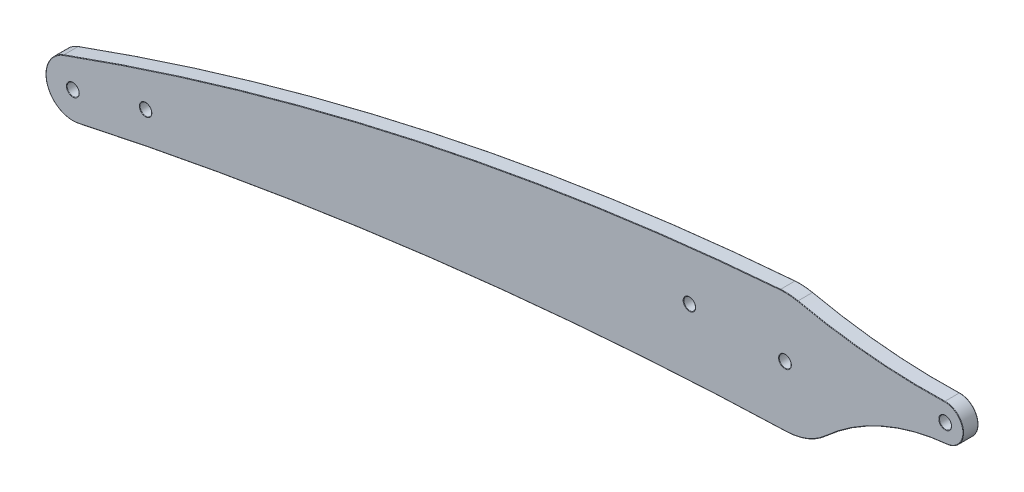
from build123d import *

# Parameters (mm, degrees)
SKETCH1_R           = 2
SKETCH1_R_2         = 1.95
BOSS_EXTRUDE1_DEPTH = 5
FILLET1_R           = 0.15


with BuildPart() as part:
    # Sketch1 → Boss-Extrude1 (new body)
    with BuildSketch(Plane.XY):
        with BuildLine():
            ThreePointArc((-276.780298859, 247.280879976), (-159.458245776, 281.177252724), (-38.627454071, 298.878891089))
            ThreePointArc((-38.627454071, 298.878891089), (-35.703409549, 298.891758843), (-32.808740213, 298.478126912))
            ThreePointArc((-32.808740213, 298.478126912), (-8.553336403, 294.720430459), (15.979700244, 293.96213667))
            ThreePointArc((15.979700244, 293.96213667), (22.150729095, 288.343420795), (16.736284207, 281.992408929))
            ThreePointArc((16.736284207, 281.992408929), (-4.892396072, 276.328147292), (-23.631877288, 264.133250235))
            ThreePointArc((-23.631877288, 264.133250235), (-29.582680643, 260.39649995), (-36.45865167, 258.948609866))
            ThreePointArc((-36.45865167, 258.948609866), (-154.786824819, 249.865033835), (-271.793567605, 230.028450028))
            ThreePointArc((-271.793567605, 230.028450028), (-282.347428026, 236.324818051), (-276.780298859, 247.280879976))
        make_face()
        with Locations((-273.701360714, 238.8239219)):
            Circle(SKETCH1_R, mode=Mode.SUBTRACT)
        with Locations((-249.527266647, 245.196768675)):
            Circle(SKETCH1_R_2, mode=Mode.SUBTRACT)
        with Locations((-68.827654746, 279.587808188)):
            Circle(SKETCH1_R_2, mode=Mode.SUBTRACT)
        with Locations((-37.077654746, 278.93902845)):
            Circle(SKETCH1_R, mode=Mode.SUBTRACT)
        with Locations((16.162679097, 287.964927424)):
            Circle(SKETCH1_R, mode=Mode.SUBTRACT)
    extrude(amount=-BOSS_EXTRUDE1_DEPTH)

    # Fillet1
    fillet1_edges = [part.edges().sort_by_distance(p)[0] for p in [
        (-4.892396072, 276.328147292, 0),
        (-29.582680643, 260.39649995, 0),
        (-154.786824819, 249.865033835, 0),
        (-282.347428026, 236.324818051, 0),
        (-29.582680643, 260.39649995, -5),
        (-4.892396072, 276.328147292, -5),
        (22.150729095, 288.343420795, -5),
        (-275.701360714, 238.8239219, -5),
        (-275.701360714, 238.8239219, 0),
        (-8.553336403, 294.720430459, -5),
        (-251.477266647, 245.196768675, -5),
        (-251.477266647, 245.196768675, 0),
        (-35.703409549, 298.891758843, -5),
        (-70.777654746, 279.587808188, -5),
        (-70.777654746, 279.587808188, 0),
        (-159.458245776, 281.177252724, -5),
        (-39.077654746, 278.93902845, -5),
        (-39.077654746, 278.93902845, 0),
        (14.162679097, 287.964927424, -5),
        (14.162679097, 287.964927424, 0),
        (-282.347428026, 236.324818051, -5),
        (-159.458245776, 281.177252724, 0),
        (-154.786824819, 249.865033835, -5),
        (-35.703409549, 298.891758843, 0),
        (-8.553336403, 294.720430459, 0),
        (22.150729095, 288.343420795, 0),
    ]]
    fillet(fillet1_edges, radius=FILLET1_R)


solid = part.part
